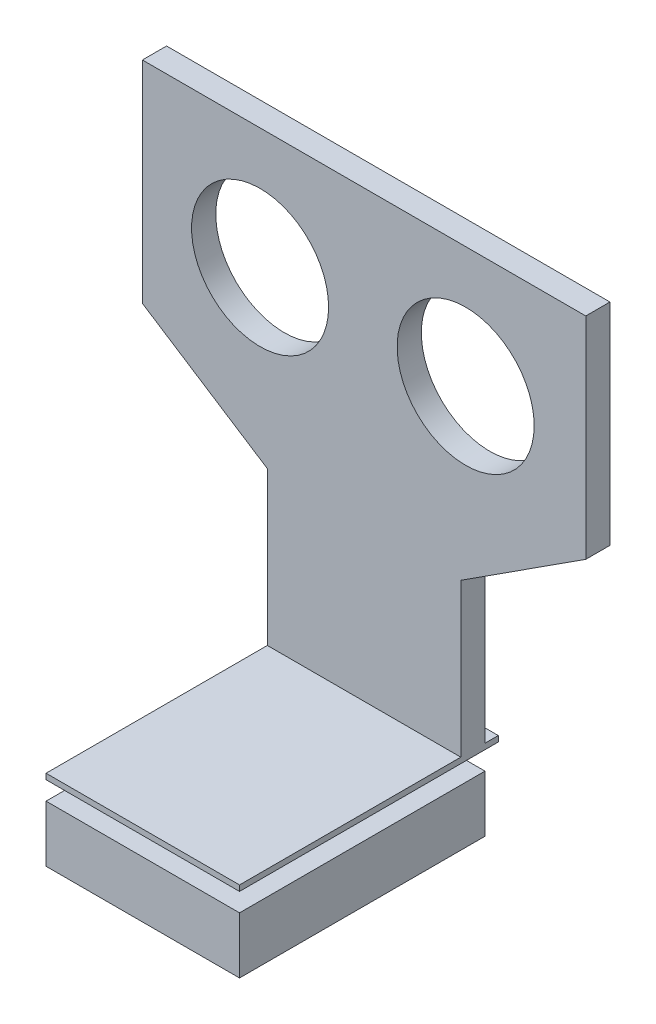
from build123d import *

# Parameters (mm, degrees)
ESBO_O1_R                     = 8.5
RESSALTO_EXTRUS_O2_DEPTH      = 3
ESBO_O2_W                     = 24
ESBO_O2_H                     = 3
RESSALTO_EXTRUS_O4_DEPTH      = 27.45
RESSALTO_EXTRUS_O4_DEPTH_BACK = 4.65
SKETCH2_W                     = 24
SKETCH2_H                     = 30.45
SKETCH2_R                     = 2.9
BOSS_EXTRUDE2_DEPTH           = 1
SKETCH3_R                     = 34.517349884
SKETCH3_R_2                   = 2.9
CUT_EXTRUDE1_DEPTH            = 2.3
SKETCH4_W                     = 24
SKETCH4_H                     = 30.45
BOSS_EXTRUDE3_DEPTH           = 6


with BuildPart() as part:
    # Esboço1 → Ressalto-extrusão2 (new body)
    with BuildSketch(Plane.XY):
        Polygon((0, 0), (0, 26.15), (55, 26.15), (55, 0), (39.5, -10), (39.5, -32), (15.5, -32), (15.5, -10), align=None)
        with Locations((40.1, 11.15)):
            Circle(ESBO_O1_R, mode=Mode.SUBTRACT)
        with Locations((14.6, 11.15)):
            Circle(ESBO_O1_R, mode=Mode.SUBTRACT)
    extrude(amount=RESSALTO_EXTRUS_O2_DEPTH)

    # Esboço2 → Ressalto-extrusão4 (add, two sides)
    with BuildSketch(Plane.XY.offset(3)) as ressalto_extrus_o4_sk:
        with Locations((27.5, -30.5)):
            Rectangle(ESBO_O2_W, ESBO_O2_H)
    extrude(amount=RESSALTO_EXTRUS_O4_DEPTH)
    extrude(ressalto_extrus_o4_sk.sketch, amount=-RESSALTO_EXTRUS_O4_DEPTH_BACK)

    # Sketch2 → Boss-Extrude2 (add)
    with BuildSketch(Plane.XZ.offset(32)):
        with Locations((27.5, 15.225)):
            Rectangle(SKETCH2_W, SKETCH2_H)
        with Locations((27.105704389, 19.6)):
            Circle(SKETCH2_R, mode=Mode.SUBTRACT)
    extrude(amount=BOSS_EXTRUDE2_DEPTH)

    # Sketch3 → Cut-Extrude1 (cut)
    with BuildSketch(Plane.XZ.offset(32)):
        with Locations((27.105704389, 19.6)):
            Circle(SKETCH3_R)
        with Locations((27.105704389, 19.6)):
            Circle(SKETCH3_R_2, mode=Mode.SUBTRACT)
    extrude(amount=-CUT_EXTRUDE1_DEPTH, mode=Mode.SUBTRACT)

    # Sketch4 → Boss-Extrude3 (add)
    with BuildSketch(Plane.XZ.offset(33)):
        with Locations((27.5, 15.225)):
            Rectangle(SKETCH4_W, SKETCH4_H)
        with BuildLine():
            ThreePointArc((29.590521878, 13.593696474), (27.188158144, 26.099477008), (24.469316606, 13.658665179))
            ThreePointArc((24.469316606, 13.658665179), (26.992674503, 10.69033729), (29.590521878, 13.593696474))
        make_face(mode=Mode.SUBTRACT)
    extrude(amount=BOSS_EXTRUDE3_DEPTH)


solid = part.part
